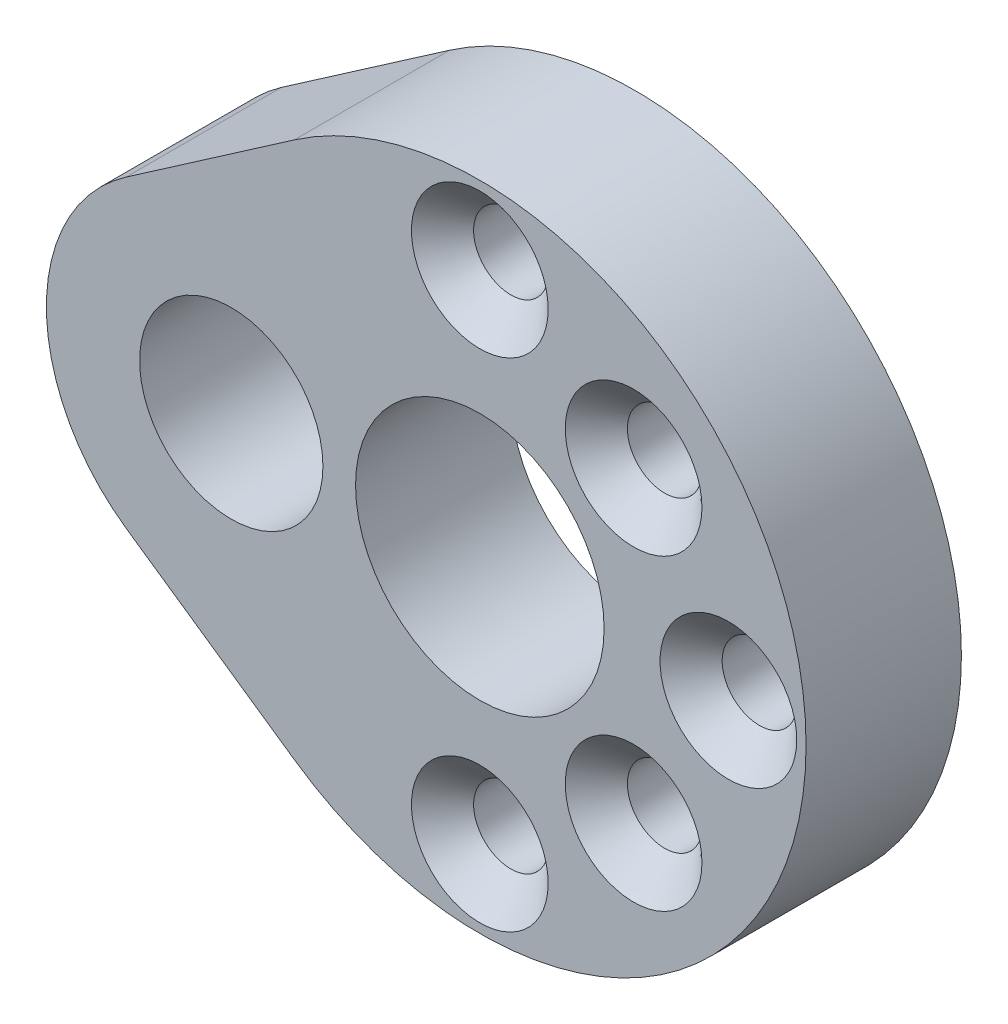
from build123d import *

# Parameters (mm, degrees)
SKETCH1_R                                           = 10.5
SKETCH1_R_2                                         = 0.8
BOSS_EXTRUDE1_DEPTH                                 = 5
SKETCH2_R                                           = 5.95
SKETCH2_R_2                                         = 2.95
BOSS_EXTRUDE2_DEPTH                                 = 5
CSK_FOR_M2_COUNTERSUNK_FLAT_HEAD_SCREW1_D           = 2.4
CSK_FOR_M2_COUNTERSUNK_FLAT_HEAD_SCREW1_CSINK_D     = 4.4
CSK_FOR_M2_COUNTERSUNK_FLAT_HEAD_SCREW1_CSINK_ANGLE = 90
SKETCH5_R                                           = 2.95
CUT_EXTRUDE1_DEPTH                                  = 5
SKETCH6_R                                           = 4
CUT_EXTRUDE2_DEPTH                                  = 5
BOSS_EXTRUDE3_DEPTH                                 = 5
SKETCH8_R                                           = 0.8
BOSS_EXTRUDE4_DEPTH                                 = 5


with BuildPart() as part:
    # Sketch1 → Boss-Extrude1 (new body)
    with BuildSketch(Plane.XY):
        Circle(SKETCH1_R)
        with Locations((-4.949747468, 4.949747468)):
            Circle(SKETCH1_R_2, mode=Mode.SUBTRACT)
        with Locations((0, 8)):
            Circle(SKETCH1_R_2, mode=Mode.SUBTRACT)
        with Locations((4.949747468, 4.949747468)):
            Circle(SKETCH1_R_2, mode=Mode.SUBTRACT)
        with Locations((8, 0)):
            Circle(SKETCH1_R_2, mode=Mode.SUBTRACT)
        with Locations((4.949747468, -4.949747468)):
            Circle(SKETCH1_R_2, mode=Mode.SUBTRACT)
        with Locations((0, -8)):
            Circle(SKETCH1_R_2, mode=Mode.SUBTRACT)
        with Locations((-4.949747468, -4.949747468)):
            Circle(SKETCH1_R_2, mode=Mode.SUBTRACT)
        with Locations((-8, 0)):
            Circle(SKETCH1_R_2, mode=Mode.SUBTRACT)
    extrude(amount=BOSS_EXTRUDE1_DEPTH)

    # Sketch2 → Boss-Extrude2 (add)
    with BuildSketch(Plane.XY.offset(5)):
        with Locations((-8, 0)):
            Circle(SKETCH2_R)
        with Locations((-8, 0)):
            Circle(SKETCH2_R_2, mode=Mode.SUBTRACT)
    extrude(amount=-BOSS_EXTRUDE2_DEPTH)

    # CSK for M2 Countersunk Flat Head Screw1 (through all)
    with Locations(Plane.XY.offset(5)):
        with Locations((4.949747468, 4.949747468), (0, 8), (0, -8), (8, 0), (4.949747468, -4.949747468)):
            CounterSinkHole(CSK_FOR_M2_COUNTERSUNK_FLAT_HEAD_SCREW1_D / 2, CSK_FOR_M2_COUNTERSUNK_FLAT_HEAD_SCREW1_CSINK_D / 2, counter_sink_angle=CSK_FOR_M2_COUNTERSUNK_FLAT_HEAD_SCREW1_CSINK_ANGLE)

    # Sketch5 → Cut-Extrude1 (cut)
    with BuildSketch(Plane.XY.offset(5)):
        with Locations((-8, 0)):
            Circle(SKETCH5_R)
    extrude(amount=-CUT_EXTRUDE1_DEPTH, mode=Mode.SUBTRACT)

    # Sketch6 → Cut-Extrude2 (cut)
    with BuildSketch(Plane.XY.offset(5)):
        Circle(SKETCH6_R)
    extrude(amount=-CUT_EXTRUDE2_DEPTH, mode=Mode.SUBTRACT)

    # Sketch7 → Boss-Extrude3 (add)
    with BuildSketch(Plane.XY.offset(5)):
        Polygon((-11.3840625, 4.893937167), (-5.971875, 8.636359707), (-6.233143588, 4.202369658), align=None)
    boss_extrude3 = extrude(amount=-BOSS_EXTRUDE3_DEPTH)

    # Mirror1: Boss-Extrude3 across plane
    add(boss_extrude3.mirror(Plane.ZX))

    # Sketch8 → Boss-Extrude4 (add)
    with BuildSketch(Plane.XY.offset(5)):
        with Locations((-4.949747468, 4.949747468)):
            Circle(SKETCH8_R)
        with Locations((-4.949747468, -4.949747468)):
            Circle(SKETCH8_R)
    extrude(amount=-BOSS_EXTRUDE4_DEPTH)


solid = part.part
